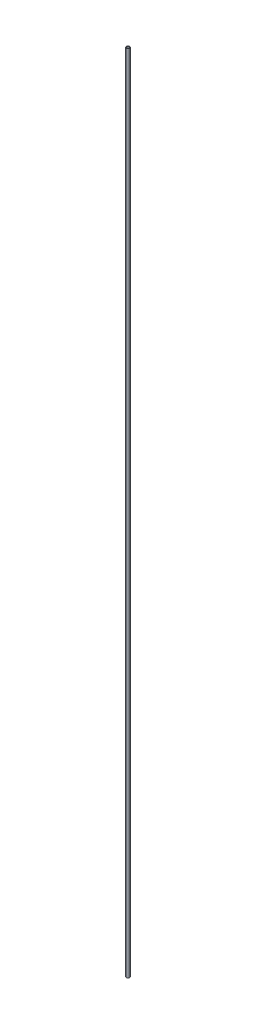
from build123d import *

# Parameters (mm, degrees)
SKETCH1_R           = 2
SKETCH1_R_2         = 1.5
BOSS_EXTRUDE1_DEPTH = 1000


with BuildPart() as part:
    # Sketch1 → Boss-Extrude1 (new body)
    with BuildSketch(Plane(origin=(0, 0, 0), x_dir=(1, 0, 0), z_dir=(0, 1, 0))):
        Circle(SKETCH1_R)
        Circle(SKETCH1_R_2, mode=Mode.SUBTRACT)
    extrude(amount=BOSS_EXTRUDE1_DEPTH)


solid = part.part
